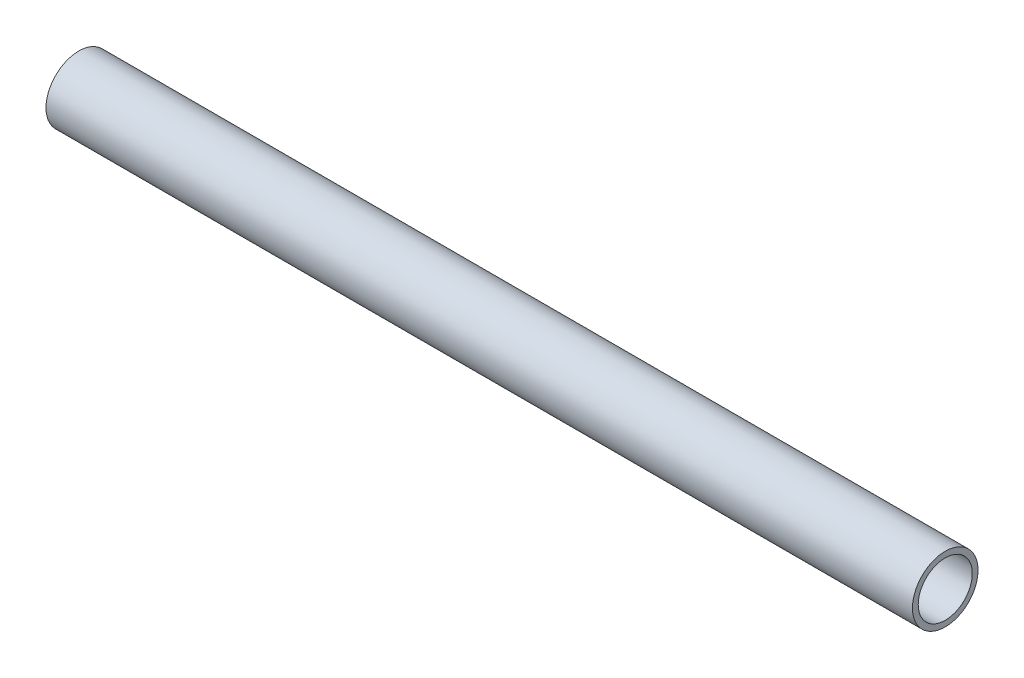
from build123d import *

# Parameters (mm, degrees)
SKETCH1_R               = 3.175
SKETCH1_R_2             = 2.6162
PIPE_0_5_SCH_40_1_DEPTH = 83.856292536


with BuildPart() as part:
    # Sketch1 → Pipe 0.5 SCH 40(1) (new body)
    with BuildSketch(Plane(origin=(-90.900701595, 684.280621263, 0), x_dir=(0, -1, 0), z_dir=(-1, 0, 0))):
        Circle(SKETCH1_R)
        Circle(SKETCH1_R_2, mode=Mode.SUBTRACT)
    extrude(amount=PIPE_0_5_SCH_40_1_DEPTH)


solid = part.part
